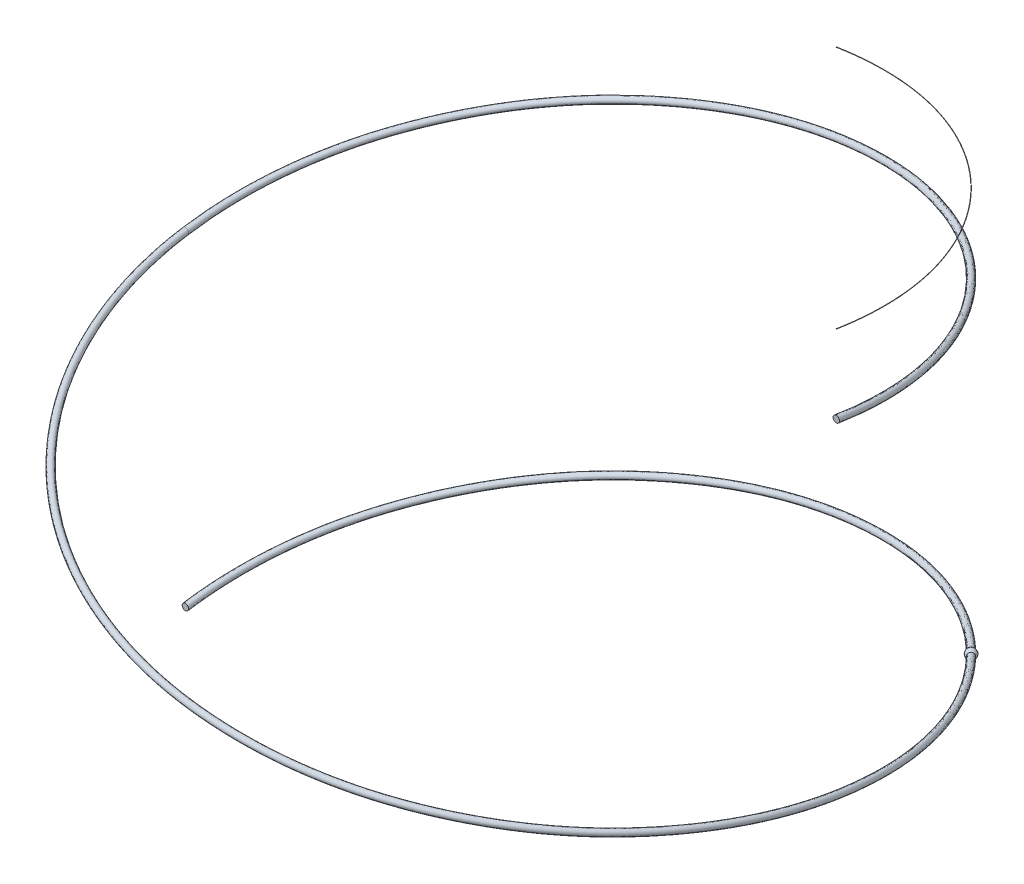
from build123d import *

# Parameters (mm, degrees)
SWEEP1_PITCH       = 5
SWEEP1_HEIGHT      = 5
SWEEP1_RADIUS      = 5
SWEEP1_START_ANGLE = -90
SKETCH4_R          = 0.05
SWEEP2_PITCH       = 5
SWEEP2_HEIGHT      = 2.5
SWEEP2_RADIUS      = 5
SWEEP2_START_ANGLE = -90
SKETCH17_R         = 0.05
SWEEP3_PITCH       = 5
SWEEP3_HEIGHT      = 1.25
SWEEP3_RADIUS      = 5
SWEEP3_START_ANGLE = 90
SKETCH29_R         = 0.0025


with BuildPart() as part:
    # Sweep1: sweep along a helix
    with BuildLine() as sweep1_path:
        add(Helix(SWEEP1_PITCH, SWEEP1_HEIGHT, SWEEP1_RADIUS, center=(0, 0, 0), direction=(0, 1, 0), lefthand=True, mode=Mode.PRIVATE).rotate(Axis((0, 0, 0), (0, 1, 0)), SWEEP1_START_ANGLE))
    # Sketch4 → Sweep1 (sweep)
    with BuildSketch(Plane.XY):
        with Locations((-5, 0)):
            Circle(SKETCH4_R)
    sweep(path=sweep1_path.line, is_frenet=True)

    # Sweep2: sweep along a helix
    with BuildLine() as sweep2_path:
        add(Helix(SWEEP2_PITCH, SWEEP2_HEIGHT, SWEEP2_RADIUS, center=(0, 5, 0), direction=(0, 1, 0), lefthand=True, mode=Mode.PRIVATE).rotate(Axis((0, 5, 0), (0, 1, 0)), SWEEP2_START_ANGLE))
    # Sketch17 → Sweep2 (sweep)
    with BuildSketch(Plane(origin=(0, 0, 0), x_dir=(-1, 0, 0), z_dir=(0, 0, -1))):
        with Locations((5, 5)):
            Circle(SKETCH17_R)
    sweep(path=sweep2_path.line, is_frenet=True)


with BuildPart() as body_2:
    # Sketch6 → Revolve4 (revolve)
    with BuildSketch(Plane(origin=(0, 0, 0), x_dir=(0.707106781, 0, -0.707106781), z_dir=(0.707106781, 0, 0.707106781))):
        with BuildLine():
            Line((5, 1.8), (5, 1.95))
            ThreePointArc((5, 1.95), (4.925, 1.875), (5, 1.8))
        make_face()
    revolve(axis=Axis((3.535533906, -998.125, -3.535533906), (0, 1, 0)))


with BuildPart() as body_3:
    # Sweep3: sweep along a helix
    with BuildLine() as sweep3_path:
        add(Helix(SWEEP3_PITCH, SWEEP3_HEIGHT, SWEEP3_RADIUS, center=(0, 8.7, 0), direction=(0, -1, 0), lefthand=True, mode=Mode.PRIVATE).rotate(Axis((0, 8.7, 0), (0, -1, 0)), SWEEP3_START_ANGLE))
    # Sketch29 → Sweep3 (sweep)
    with BuildSketch(Plane.XY):
        with Locations((5, 8.7)):
            Circle(SKETCH29_R)
    sweep(path=sweep3_path.line, is_frenet=True)


solid = Compound([part.part, body_2.part, body_3.part])
